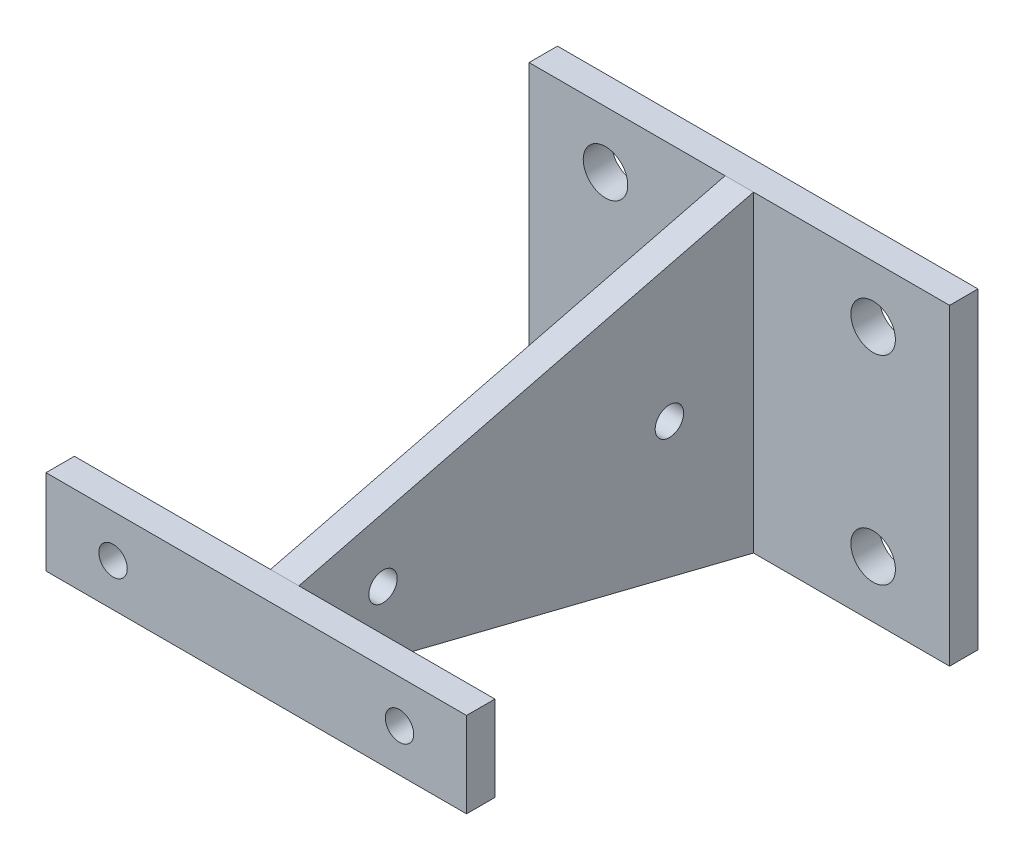
from build123d import *

# Parameters (mm, degrees)
SKETCH1_W           = 46.99
SKETCH1_H           = 9.525
SKETCH1_R           = 1.5875
BOSS_EXTRUDE1_DEPTH = 3.175
SKETCH2_R           = 1.5875
BOSS_EXTRUDE2_DEPTH = 1.5875
SKETCH4_W           = 46.99
SKETCH4_H           = 34.925
SKETCH4_R           = 2.4892
BOSS_EXTRUDE3_DEPTH = 3.175


with BuildPart() as part:
    # Sketch1 → Boss-Extrude1 (new body)
    with BuildSketch(Plane.XY):
        Rectangle(SKETCH1_W, SKETCH1_H)
        with Locations((-16.002, 0)):
            Circle(SKETCH1_R, mode=Mode.SUBTRACT)
        with Locations((16.002, 0)):
            Circle(SKETCH1_R, mode=Mode.SUBTRACT)
    extrude(amount=BOSS_EXTRUDE1_DEPTH)

    # Sketch2 → Boss-Extrude2 (add, symmetric)
    with BuildSketch(Plane(origin=(0, 0, 0), x_dir=(0, 0, -1), z_dir=(1, 0, 0))):
        Polygon((50.8, 17.4625), (0, 4.7625), (0, -4.7625), (50.8, -17.4625), align=None)
        with Locations((9.398, 0)):
            Circle(SKETCH2_R, mode=Mode.SUBTRACT)
        with Locations((41.402, 0)):
            Circle(SKETCH2_R, mode=Mode.SUBTRACT)
    extrude(amount=BOSS_EXTRUDE2_DEPTH, both=True)

    # Sketch4 → Boss-Extrude3 (add)
    with BuildSketch(Plane(origin=(0, 0, -50.8), x_dir=(-1, 0, 0), z_dir=(0, 0, -1))):
        Rectangle(SKETCH4_W, SKETCH4_H)
        with Locations((-14.951363636, 11.1125)):
            Circle(SKETCH4_R, mode=Mode.SUBTRACT)
        with Locations((14.951363636, 11.1125)):
            Circle(SKETCH4_R, mode=Mode.SUBTRACT)
        with Locations((14.951363636, -11.1125)):
            Circle(SKETCH4_R, mode=Mode.SUBTRACT)
        with Locations((-14.951363636, -11.1125)):
            Circle(SKETCH4_R, mode=Mode.SUBTRACT)
    extrude(amount=BOSS_EXTRUDE3_DEPTH)


solid = part.part
